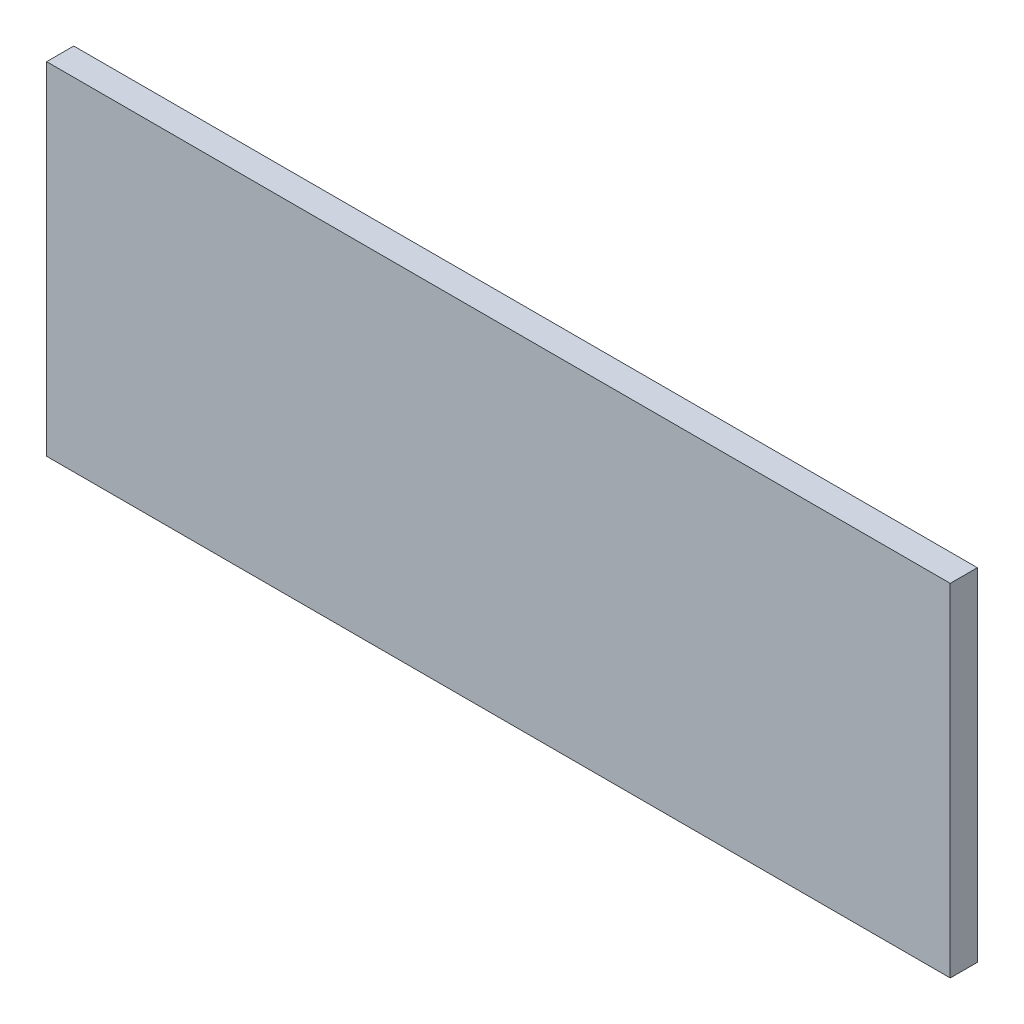
from build123d import *

# Parameters (mm, degrees)
SKETCH1_W           = 1115
SKETCH1_H           = 421.74
BOSS_EXTRUDE1_DEPTH = 33.45


with BuildPart() as part:
    # Sketch1 → Boss-Extrude1 (new body)
    with BuildSketch(Plane.XY):
        Rectangle(SKETCH1_W, SKETCH1_H)
    extrude(amount=BOSS_EXTRUDE1_DEPTH)


solid = part.part
